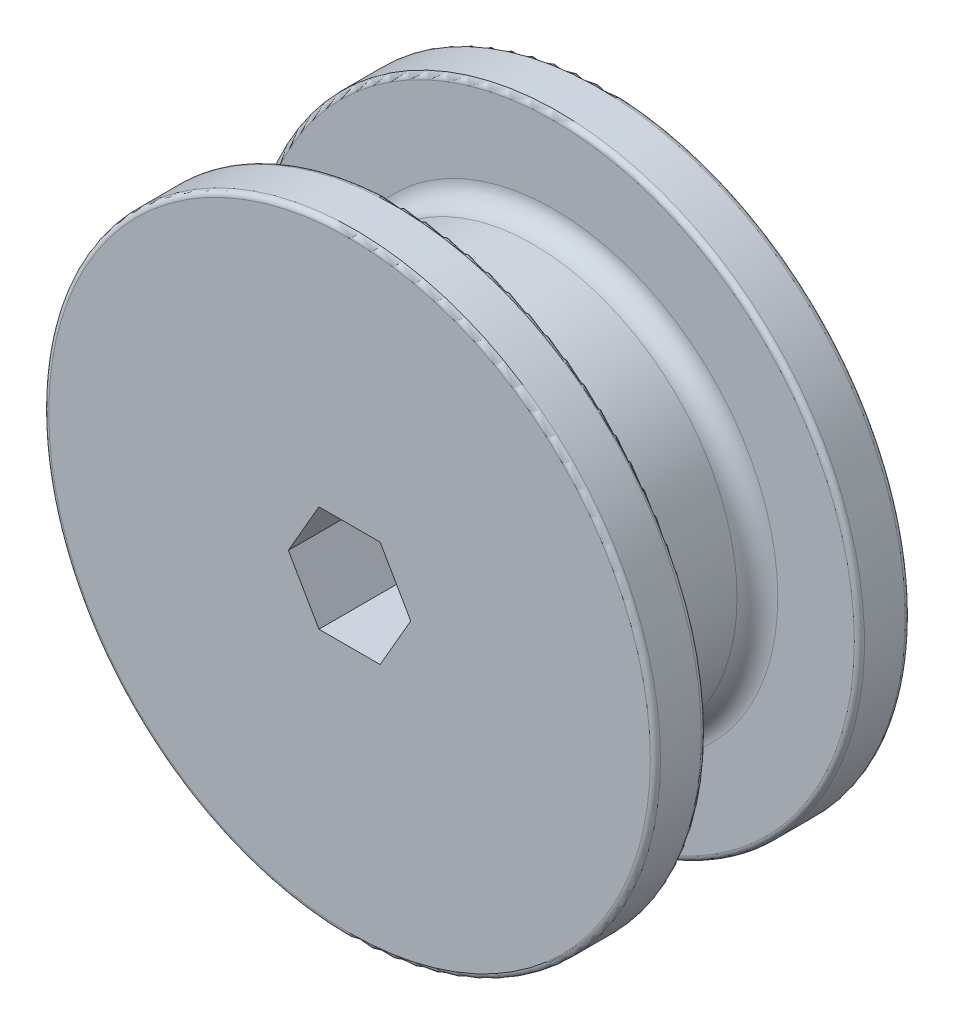
from build123d import *

# Parameters (mm, degrees)
SKETCH1_R           = 25.4
BOSS_EXTRUDE1_DEPTH = 19.05
SKETCH2_R           = 38.1
BOSS_EXTRUDE2_DEPTH = 6.35
SKETCH3_R           = 38.1
BOSS_EXTRUDE3_DEPTH = 6.35
CUT_EXTRUDE1_DEPTH  = 32.75
FILLET1_R           = 2.54
FILLET2_R           = 0.635


with BuildPart() as part:
    # Sketch1 → Boss-Extrude1 (new body)
    with BuildSketch(Plane.XY):
        Circle(SKETCH1_R)
    extrude(amount=BOSS_EXTRUDE1_DEPTH)

    # Sketch2 → Boss-Extrude2 (add)
    with BuildSketch(Plane.XY.offset(19.05)):
        Circle(SKETCH2_R)
    extrude(amount=BOSS_EXTRUDE2_DEPTH)

    # Sketch3 → Boss-Extrude3 (add)
    with BuildSketch(Plane(origin=(0, 0, 0), x_dir=(-1, 0, 0), z_dir=(0, 0, -1))):
        Circle(SKETCH3_R)
    extrude(amount=BOSS_EXTRUDE3_DEPTH)

    # Sketch4 → Cut-Extrude1 (cut, through all)
    with BuildSketch(Plane.XY.offset(25.4)):
        Polygon((7.621023553, 0), (3.810511777, 6.6), (-3.810511777, 6.6), (-7.621023553, 0), (-3.810511777, -6.6), (3.810511777, -6.6), align=None)
    extrude(amount=-CUT_EXTRUDE1_DEPTH, mode=Mode.SUBTRACT)

    # Fillet1
    fillet1_edges = [part.edges().sort_by_distance(p)[0] for p in [
        (-25.4, 0, 19.05),
        (-25.4, 0, 0),
    ]]
    fillet(fillet1_edges, radius=FILLET1_R)

    # Fillet2
    fillet2_edges = [part.edges().sort_by_distance(p)[0] for p in [
        (38.1, 0, -6.35),
        (-38.1, 0, 19.05),
        (-38.1, 0, 25.4),
        (38.1, 0, 0),
    ]]
    fillet(fillet2_edges, radius=FILLET2_R)


solid = part.part
